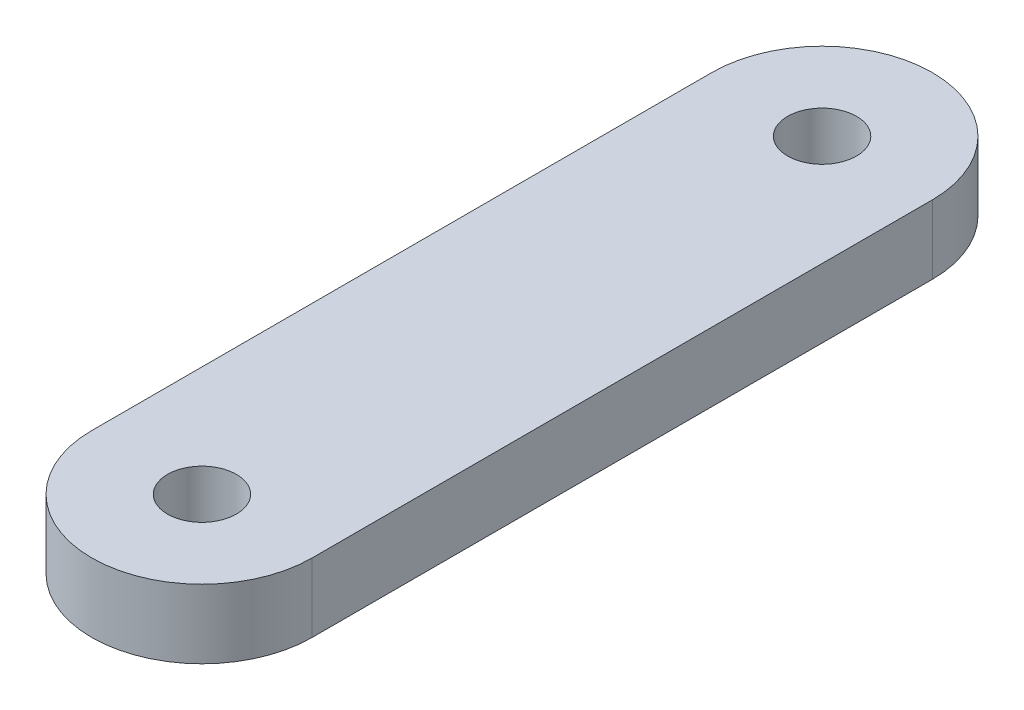
from build123d import *

# Parameters (mm, degrees)
SKETCH1_R           = 1.25
BOSS_EXTRUDE1_DEPTH = 2.5


with BuildPart() as part:
    # Sketch1 → Boss-Extrude1 (new body)
    with BuildSketch(Plane(origin=(0, 0, 0), x_dir=(1, 0, 0), z_dir=(0, 1, 0))):
        with BuildLine():
            Line((-4, 0), (-4, 22.5))
            ThreePointArc((-4, 22.5), (0, 26.5), (4, 22.5))
            Line((4, 22.5), (4, 0))
            ThreePointArc((4, 0), (0, -4), (-4, 0))
        make_face()
        with Locations((0, 22.5)):
            Circle(SKETCH1_R, mode=Mode.SUBTRACT)
        Circle(SKETCH1_R, mode=Mode.SUBTRACT)
    extrude(amount=BOSS_EXTRUDE1_DEPTH)


solid = part.part
